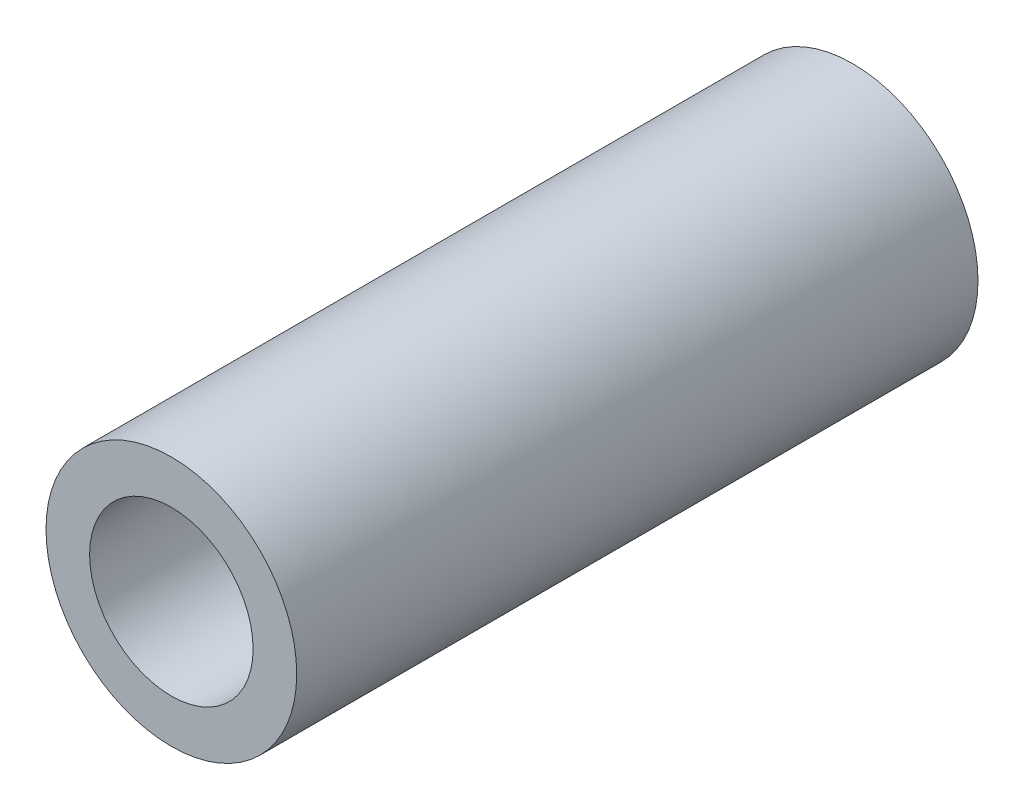
from build123d import *

# Parameters (mm, degrees)
SKETCH1_R           = 4.6
SKETCH1_R_2         = 3
BOSS_EXTRUDE1_DEPTH = 25


with BuildPart() as part:
    # Sketch1 → Boss-Extrude1 (new body)
    with BuildSketch(Plane.XY):
        Circle(SKETCH1_R)
        Circle(SKETCH1_R_2, mode=Mode.SUBTRACT)
    extrude(amount=-BOSS_EXTRUDE1_DEPTH)


solid = part.part
